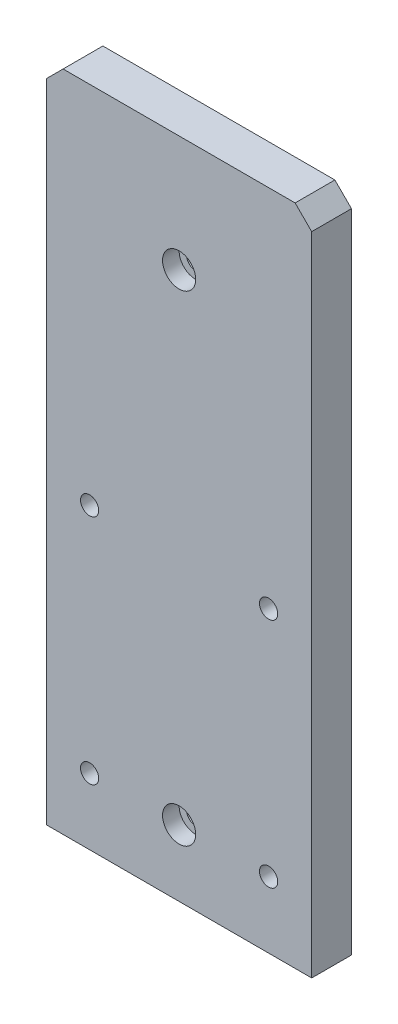
from build123d import *

# Parameters (mm, degrees)
BOSS_EXTRUDE1_DEPTH                             = 12
CBORE_FOR_M5_SOCKET_HEAD_CAP_SCREW1_D           = 5.5
CBORE_FOR_M5_SOCKET_HEAD_CAP_SCREW1_CBORE_D     = 10
CBORE_FOR_M5_SOCKET_HEAD_CAP_SCREW1_CBORE_DEPTH = 5
M5X0_8_TAPPED_HOLE1_D                           = 4.2
M5X0_8_TAPPED_HOLE1_DEPTH                       = 14
M5X0_8_TAPPED_HOLE1_TIP                         = 1.2618073
SKETCH6_R                                       = 2
CUT_EXTRUDE1_DEPTH                              = 8
CBORE_FOR_M5_SOCKET_HEAD_CAP_SCREW2_D           = 5.5
CBORE_FOR_M5_SOCKET_HEAD_CAP_SCREW2_CBORE_D     = 10
CBORE_FOR_M5_SOCKET_HEAD_CAP_SCREW2_CBORE_DEPTH = 5


with BuildPart() as part:
    # Sketch1 → Boss-Extrude1 (new body)
    with BuildSketch(Plane.XY):
        Polygon((-40, 0), (40, 0), (40, 195), (35, 200), (-35, 200), (-40, 195), align=None)
    extrude(amount=BOSS_EXTRUDE1_DEPTH)

    # CBORE for M5 Socket Head Cap Screw1 (through all)
    with Locations(Plane.XY.offset(12)):
        with Locations((0, 20), (0, 165)):
            CounterBoreHole(CBORE_FOR_M5_SOCKET_HEAD_CAP_SCREW1_D / 2, CBORE_FOR_M5_SOCKET_HEAD_CAP_SCREW1_CBORE_D / 2, CBORE_FOR_M5_SOCKET_HEAD_CAP_SCREW1_CBORE_DEPTH)

    # M5x0.8 Tapped Hole1
    with Locations(Plane.XZ):
        with Locations((-25, 6), (25, 6)):
            Hole(M5X0_8_TAPPED_HOLE1_D / 2, depth=M5X0_8_TAPPED_HOLE1_DEPTH)
            with Locations((0, 0, -(M5X0_8_TAPPED_HOLE1_DEPTH + M5X0_8_TAPPED_HOLE1_TIP / 2))):  # 118° drill point
                Cone(0, M5X0_8_TAPPED_HOLE1_D / 2, M5X0_8_TAPPED_HOLE1_TIP, mode=Mode.SUBTRACT)

    # Sketch6 → Cut-Extrude1 (cut)
    with BuildSketch(Plane(origin=(0, 0, 0), x_dir=(1, 0, 0), z_dir=(0, 1, 0))):
        with Locations((33, -6)):
            Circle(SKETCH6_R)
        with Locations((-33, -6)):
            Circle(SKETCH6_R)
    extrude(amount=CUT_EXTRUDE1_DEPTH, mode=Mode.SUBTRACT)

    # CBORE for M5 Socket Head Cap Screw2 (through all)
    with Locations(Plane(origin=(0, 0, 0), x_dir=(-1, 0, 0), z_dir=(0, 0, -1))):
        with Locations((27, 20), (27, 90), (-27, 90), (-27, 20)):
            CounterBoreHole(CBORE_FOR_M5_SOCKET_HEAD_CAP_SCREW2_D / 2, CBORE_FOR_M5_SOCKET_HEAD_CAP_SCREW2_CBORE_D / 2, CBORE_FOR_M5_SOCKET_HEAD_CAP_SCREW2_CBORE_DEPTH)


solid = part.part
